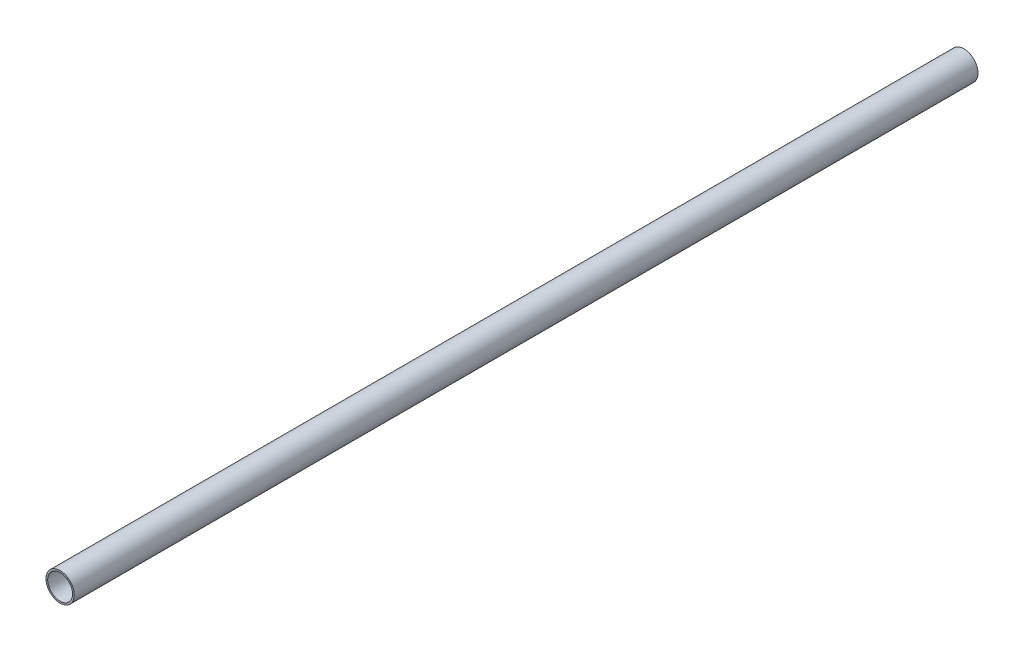
from build123d import *

# Parameters (mm, degrees)
SKETCH1_R           = 12.5
SKETCH1_R_2         = 11
BOSS_EXTRUDE1_DEPTH = 800


with BuildPart() as part:
    # Sketch1 → Boss-Extrude1 (new body)
    with BuildSketch(Plane.XY):
        Circle(SKETCH1_R)
        Circle(SKETCH1_R_2, mode=Mode.SUBTRACT)
    extrude(amount=BOSS_EXTRUDE1_DEPTH)


solid = part.part
